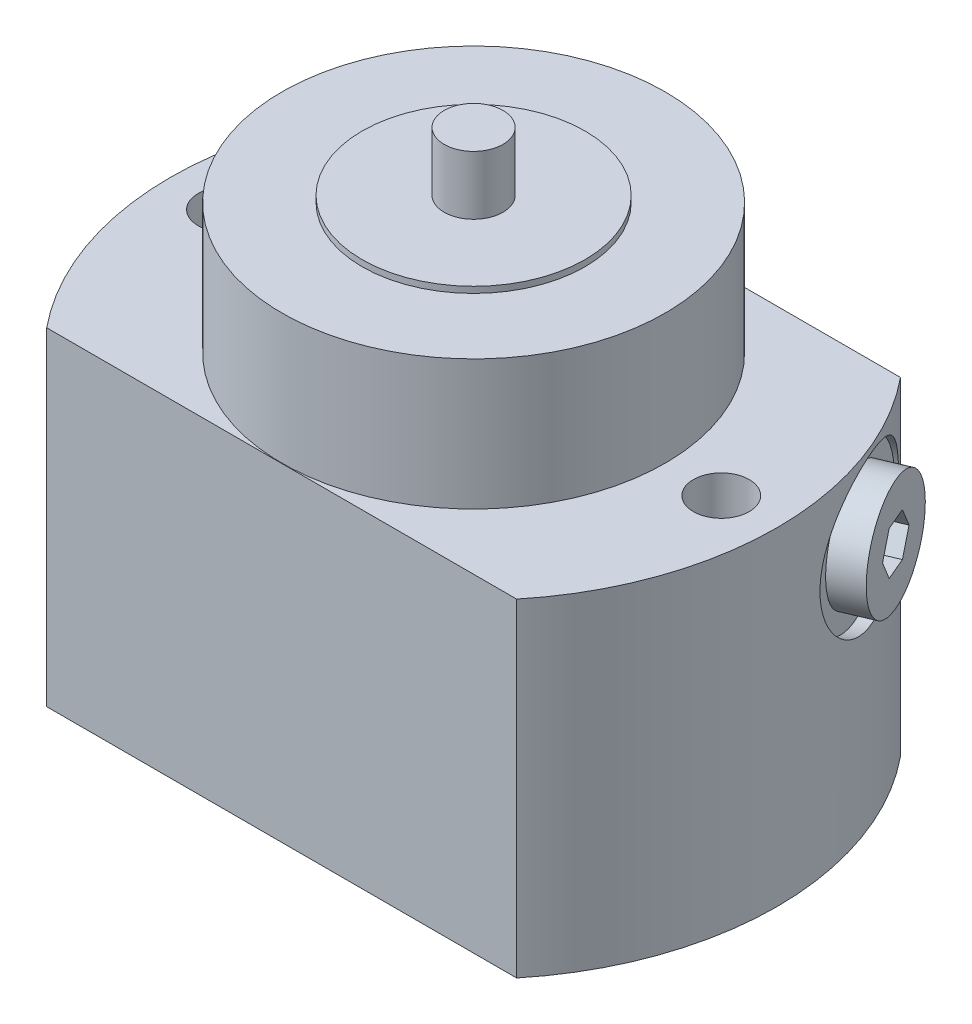
from build123d import *

# Parameters (mm, degrees)
EXTRUDE1_DEPTH     = 53
HOLE1_D            = 9
HOLE1_DEPTH        = 53
SKETCH5_R          = 4
CUT_EXTRUDE1_DEPTH = 4
SKETCH6_R          = 5.5
CUT_EXTRUDE2_DEPTH = 3
SKETCH7_R          = 2
CUT_EXTRUDE3_DEPTH = 33
CUT_EXTRUDE4_DEPTH = 5


with BuildPart() as part:
    # Sketch1 → Extrude1 (new body)
    with BuildSketch(Plane(origin=(0, 0, 0), x_dir=(1, 0, 0), z_dir=(0, 1, 0))):
        with BuildLine():
            Line((-37.947331922, 31), (37.947331922, 31))
            ThreePointArc((37.947331922, 31), (49, 0), (37.947331922, -31))
            Line((37.947331922, -31), (-37.947331922, -31))
            ThreePointArc((-37.947331922, -31), (-49, 0), (-37.947331922, 31))
        make_face()
    extrude(amount=EXTRUDE1_DEPTH)

    # Sketch2 → Revolve1 (revolve)
    with BuildSketch(Plane.XY, mode=Mode.PRIVATE) as revolve1_sk:
        Polygon((0, 84.5), (-4.75, 84.5), (-4.75, 75), (-18, 75), (-18, 74), (-30.95, 74), (-30.95, 53), (0, 53), align=None)
    revolve(revolve1_sk.sketch.rotate(Axis((0, 0, 0), (0, 1, 0)), 270), axis=Axis((0, 0, 0), (0, 1, 0)))  # turned: the seam where the file's is

    # Hole1
    with Locations(Plane(origin=(0, 53, 0), x_dir=(-1, 0, 0), z_dir=(0, 1, 0))):
        with Locations((40, 0), (-40, 0)):
            Hole(HOLE1_D / 2, depth=HOLE1_DEPTH)

    # Sketch5 → Cut-Extrude1 (cut)
    with BuildSketch(Plane.XZ):
        with Locations(Location((0, 0, 0), (0, 0, 270))):  # turned: the seam where the file's is
            Circle(SKETCH5_R)
    extrude(amount=-CUT_EXTRUDE1_DEPTH, mode=Mode.SUBTRACT)

    # Sketch6 → Cut-Extrude2 (cut)
    with BuildSketch(Plane.XZ):
        with Locations(Location((31, -13, 0), (0, 0, 270))):  # turned: the seam where the file's is
            Circle(SKETCH6_R)
    extrude(amount=-CUT_EXTRUDE2_DEPTH, mode=Mode.SUBTRACT)

    # Sketch7 → Cut-Extrude3 (cut)
    with BuildSketch(Plane.XZ.offset(-3)):
        with Locations(Location((31, -13, 0), (0, 0, 270))):  # turned: the seam where the file's is
            Circle(SKETCH7_R)
    extrude(amount=-CUT_EXTRUDE3_DEPTH, mode=Mode.SUBTRACT)

    # Sketch8 → Cut-Revolve1 (revolve, cut)
    with BuildSketch(Plane(origin=(0, 0, 0), x_dir=(0.920504853, 0, -0.390731128), z_dir=(0.390731128, 0, 0.920504853)), mode=Mode.PRIVATE) as cut_revolve1_sk:
        Polygon((49, 28), (47, 28), (47, 33.4215), (45.517364509, 34.2775), (32, 34.2775), (32, 40), (49, 40), align=None)
    revolve(cut_revolve1_sk.sketch.rotate(Axis((47.484793311, 40, -20.156098913), (-0.920504853, 0, 0.390731128)), 270), axis=Axis((47.484793311, 40, -20.156098913), (-0.920504853, 0, 0.390731128)), mode=Mode.SUBTRACT)  # turned: the seam where the file's is

    # Sketch9 → Revolve2 (revolve)
    with BuildSketch(Plane(origin=(0, 0, 0), x_dir=(0.920504853, 0, -0.390731128), z_dir=(0.390731128, 0, 0.920504853)), mode=Mode.PRIVATE) as revolve2_sk:
        Polygon((47, 31), (47, 34.2775), (38, 34.2775), (37, 35.2775), (37, 40), (52, 40), (52, 31), align=None)
    revolve(revolve2_sk.sketch.rotate(Axis((53.930450878, 40, -22.892118224), (-0.920504853, 0, 0.390731128)), 270), axis=Axis((53.930450878, 40, -22.892118224), (-0.920504853, 0, 0.390731128)))  # turned: the seam where the file's is

    # Sketch10 → Cut-Extrude4 (cut)
    with BuildSketch(Plane(origin=(47.86625238, 0, -20.318018681), x_dir=(-0.390731128, 0, -0.920504853), z_dir=(0.920504853, 0, -0.390731128))):
        Polygon((4.041451884, 40), (2.020725942, 43.5), (-2.020725942, 43.5), (-4.041451884, 40), (-2.020725942, 36.5), (2.020725942, 36.5), align=None)
    extrude(amount=-CUT_EXTRUDE4_DEPTH, mode=Mode.SUBTRACT)


solid = part.part
